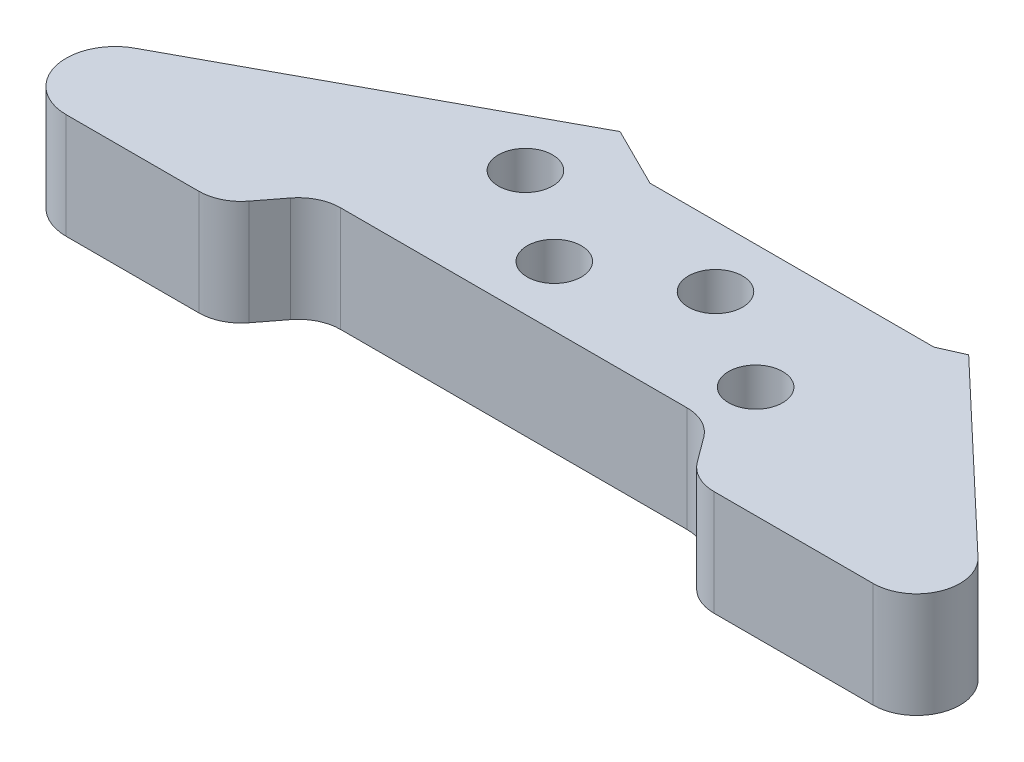
from build123d import *

# Parameters (mm, degrees)
SKETCH1_R           = 3.2639
BOSS_EXTRUDE1_DEPTH = 12.7


with BuildPart() as part:
    # Sketch1 → Boss-Extrude1 (new body)
    with BuildSketch(Plane(origin=(0, 0, 0), x_dir=(1, 0, 0), z_dir=(0, 1, 0))):
        with BuildLine():
            Line((98.733031573, -68.985835228), (100.942599672, -71.978006872))
            ThreePointArc((100.942599672, -71.978006872), (102.740427245, -73.495514847), (105.029143887, -74.040299732))
            Line((105.029143887, -74.040299732), (124.201892168, -74.040299732))
            ThreePointArc((124.201892168, -74.040299732), (129.062693158, -70.745465469), (127.802444272, -65.010041176))
            Line((127.802444272, -65.010041176), (106.094318665, -44.426787292))
            Line((106.094318665, -44.426787292), (103.19820861, -45.713487798))
            Line((103.19820861, -45.713487798), (68.977352979, -45.713487798))
            Line((68.977352979, -45.713487798), (61.792374607, -42.131557151))
            Line((61.792374607, -42.131557151), (24.038270246, -62.563232545))
            ThreePointArc((24.038270246, -62.563232545), (20.915380805, -69.188017292), (26.654079797, -73.738571684))
            Line((26.654079797, -73.738571684), (42.658611745, -73.738571684))
            ThreePointArc((42.658611745, -73.738571684), (44.904764604, -73.215017375), (46.687932027, -71.752271422))
            Line((46.687932027, -71.752271422), (48.870340124, -68.909842629))
            ThreePointArc((48.870340124, -68.909842629), (50.653507547, -67.447096676), (52.899660406, -66.923542367))
            Line((52.899660406, -66.923542367), (94.646487358, -66.923542367))
            ThreePointArc((94.646487358, -66.923542367), (96.935204, -67.468327252), (98.733031573, -68.985835228))
        make_face()
        with Locations((60.150170667, -51.891201826)):
            Circle(SKETCH1_R, mode=Mode.SUBTRACT)
        with Locations((71.3764156, -59.641849895)):
            Circle(SKETCH1_R, mode=Mode.SUBTRACT)
        with Locations((84.237729699, -53.077081169)):
            Circle(SKETCH1_R, mode=Mode.SUBTRACT)
        with Locations((96.63028976, -60.633621731)):
            Circle(SKETCH1_R, mode=Mode.SUBTRACT)
    extrude(amount=BOSS_EXTRUDE1_DEPTH)


solid = part.part
